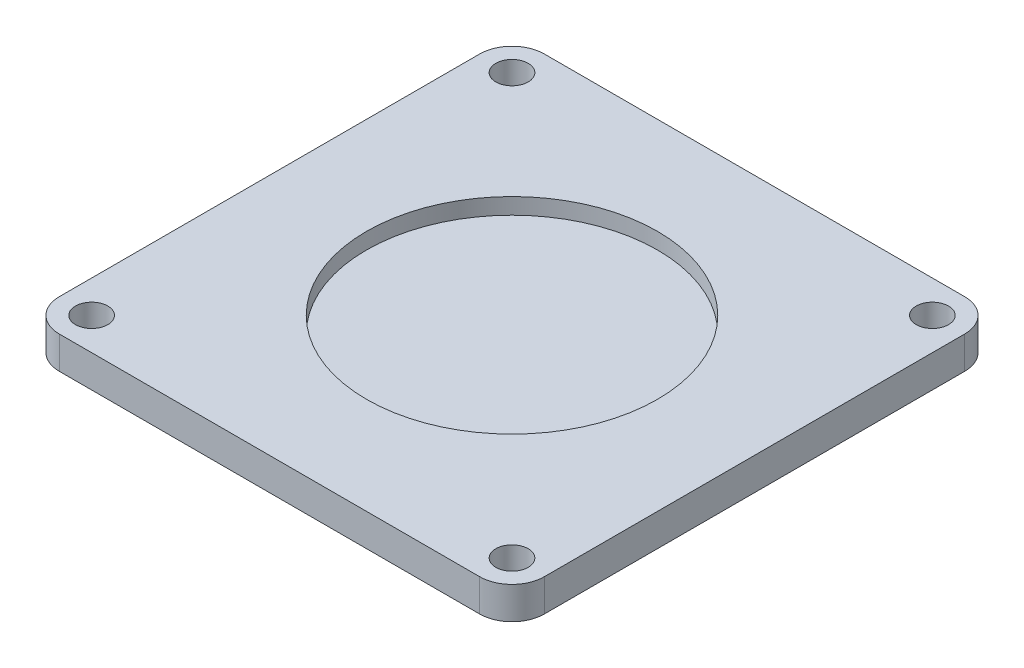
from build123d import *

# Parameters (mm, degrees)
SKETCH1_W           = 30
SKETCH1_H           = 30
BOSS_EXTRUDE1_DEPTH = 2
SKETCH2_R           = 9
CUT_EXTRUDE1_DEPTH  = 1
SKETCH3_R           = 10
BOSS_EXTRUDE2_DEPTH = 3
SKETCH4_R           = 1
BOSS_EXTRUDE3_DEPTH = 3
FILLET1_R           = 1
CHAMFER2_SIZE       = 0.5
CHAMFER2_SIZE2      = 0.08816349
SKETCH5_R           = 1
CUT_EXTRUDE2_DEPTH  = 3
FILLET2_R           = 2


with BuildPart() as part:
    # Sketch1 → Boss-Extrude1 (new body)
    with BuildSketch(Plane(origin=(0, 0, 0), x_dir=(1, 0, 0), z_dir=(0, 1, 0))):
        Rectangle(SKETCH1_W, SKETCH1_H)
    extrude(amount=BOSS_EXTRUDE1_DEPTH)

    # Sketch2 → Cut-Extrude1 (cut)
    with BuildSketch(Plane(origin=(0, 2, 0), x_dir=(1, 0, 0), z_dir=(0, 1, 0))):
        Circle(SKETCH2_R)
    extrude(amount=-CUT_EXTRUDE1_DEPTH, mode=Mode.SUBTRACT)

    # Sketch3 → Boss-Extrude2 (add)
    with BuildSketch(Plane.XZ):
        Circle(SKETCH3_R)
    extrude(amount=BOSS_EXTRUDE2_DEPTH)

    # Sketch4 → Boss-Extrude3 (add)
    with BuildSketch(Plane.XZ.offset(3)):
        Circle(SKETCH4_R)
    extrude(amount=BOSS_EXTRUDE3_DEPTH)

    # Fillet1
    fillet1_edges = [part.edges().sort_by_distance(p)[0] for p in [
        (-10, -3, 0),
    ]]
    fillet(fillet1_edges, radius=FILLET1_R)

    # Chamfer2
    chamfer2_edges = [part.edges().sort_by_distance(p)[0] for p in [
        (-1, -6, 0),
    ]]
    chamfer2_side = [part.faces().sort_by_distance(p)[0] for p in [
        (-1, -4.5, 0),
    ]]
    chamfer(chamfer2_edges, length=CHAMFER2_SIZE, length2=CHAMFER2_SIZE2, reference=chamfer2_side[0])

    # Sketch5 → Cut-Extrude2 (cut, through all)
    with BuildSketch(Plane.XZ):
        with Locations((-13, 13)):
            Circle(SKETCH5_R)
        with Locations((13, 13)):
            Circle(SKETCH5_R)
        with Locations((13, -13)):
            Circle(SKETCH5_R)
        with Locations((-13, -13)):
            Circle(SKETCH5_R)
    extrude(amount=-CUT_EXTRUDE2_DEPTH, mode=Mode.SUBTRACT)

    # Fillet2
    fillet2_edges = [part.edges().sort_by_distance(p)[0] for p in [
        (15, 1, 15),
        (-15, 1, 15),
        (-15, 1, -15),
        (15, 1, -15),
    ]]
    fillet(fillet2_edges, radius=FILLET2_R)


solid = part.part
